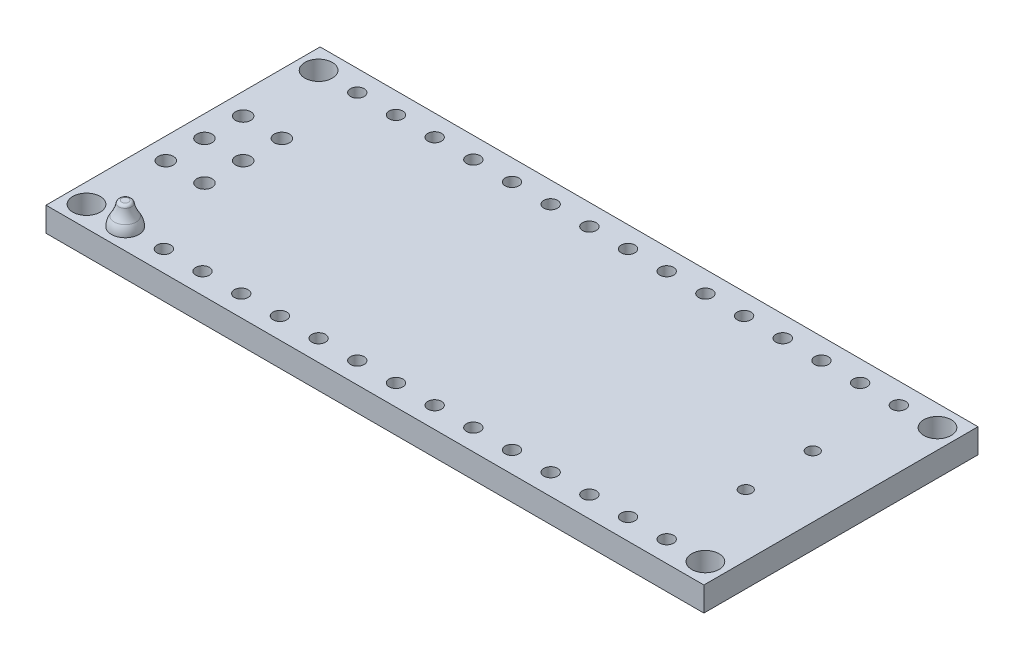
from build123d import *

# Parameters (mm, degrees)
SKETCH1_W            = 43.2
SKETCH1_H            = 18
BOSS_EXTRUDE2_DEPTH  = 1.6
SKETCH2_R            = 0.45
CUT_EXTRUDE2_DEPTH   = 1.6
LPATTERN1_COUNT      = 15
LPATTERN1_PITCH      = 2.54
SKETCH3_R            = 0.5
CUT_EXTRUDE4_DEPTH   = 1.6
SKETCH4_R            = 0.9
CUT_EXTRUDE5_DEPTH   = 1.6
LPATTERN3_COUNT      = 2
LPATTERN3_PITCH      = 2.54
LPATTERN3_COUNT_DIR2 = 3
LPATTERN3_PITCH_DIR2 = 2.54
SKETCH9_R            = 0.4
CUT_EXTRUDE6_DEPTH   = 10


with BuildPart() as part:
    # Sketch1 → Boss-Extrude2 (new body)
    with BuildSketch(Plane(origin=(0, 0, 0), x_dir=(1, 0, 0), z_dir=(0, 1, 0))):
        with Locations((17.78, 7.62)):
            Rectangle(SKETCH1_W, SKETCH1_H)
    extrude(amount=BOSS_EXTRUDE2_DEPTH)

    # Sketch2 → Cut-Extrude2 (cut)
    with BuildSketch(Plane(origin=(0, 0, 0), x_dir=(1, 0, 0), z_dir=(0, 1, 0))):
        Circle(SKETCH2_R)
        with Locations((0, 15.24)):
            Circle(SKETCH2_R)
    cut_extrude2 = extrude(amount=CUT_EXTRUDE2_DEPTH, mode=Mode.SUBTRACT)

    # LPattern1: Cut-Extrude2 ×15
    with Locations(*[(i * LPATTERN1_PITCH, 0, 0) for i in range(1, LPATTERN1_COUNT)]):
        add(cut_extrude2, mode=Mode.SUBTRACT)

    # Sketch3 → Cut-Extrude4 (cut)
    with BuildSketch(Plane(origin=(0, 0, 0), x_dir=(1, 0, 0), z_dir=(0, 1, 0))):
        with Locations((0.127, 10.16)):
            Circle(SKETCH3_R)
        with Locations((-2.413, 10.16)):
            Circle(SKETCH3_R)
        with Locations((-2.413, 7.62)):
            Circle(SKETCH3_R)
        with Locations((-2.413, 5.08)):
            Circle(SKETCH3_R)
        with Locations((0.127, 5.08)):
            Circle(SKETCH3_R)
        with Locations((0.127, 7.62)):
            Circle(SKETCH3_R)
    extrude(amount=CUT_EXTRUDE4_DEPTH, mode=Mode.SUBTRACT)

    # Sketch4 → Cut-Extrude5 (cut)
    with BuildSketch(Plane(origin=(0, 0, 0), x_dir=(1, 0, 0), z_dir=(0, 1, 0))):
        with Locations((38.1, 15.24)):
            Circle(SKETCH4_R)
        with Locations((38.1, 0)):
            Circle(SKETCH4_R)
        with Locations((-2.54, 0)):
            Circle(SKETCH4_R)
        with Locations((-2.54, 15.24)):
            Circle(SKETCH4_R)
    extrude(amount=CUT_EXTRUDE5_DEPTH, mode=Mode.SUBTRACT)

    # Sketch6 → Revolve1 (revolve)
    with BuildSketch(Plane(origin=(0, 0, 0), x_dir=(0, 0, -1), z_dir=(1, 0, 0))):
        with BuildLine():
            Line((0, 1.6), (0.9, 1.6))
            ThreePointArc((0.9, 1.6), (0.852442497, 1.91994498), (0.713882199, 2.212224898))
            ThreePointArc((0.713882199, 2.212224898), (0.530499248, 2.558589224), (0.422081551, 2.93520993))
            ThreePointArc((0.422081551, 2.93520993), (0.353575878, 3.053365554), (0.225205293, 3.1))
            Line((0.225205293, 3.1), (0, 3.1))
            Line((0, 3.1), (0, 1.6))
        make_face()
    revolve(axis=Axis((0, 1.372239532, 0), (0, 1, 0)))

    # Sketch7 → Revolve2 (revolve)
    with BuildSketch(Plane.XY.offset(-5.08)):
        with BuildLine():
            Line((0.127, 0), (1.027, 0))
            ThreePointArc((1.027, 0), (0.970551628, -0.347850543), (0.807, -0.66))
            ThreePointArc((0.807, -0.66), (0.629174555, -0.974977034), (0.537980562, -1.325))
            ThreePointArc((0.537980562, -1.325), (0.471836779, -1.45), (0.339549213, -1.5))
            Line((0.339549213, -1.5), (0.127, -1.5))
            Line((0.127, -1.5), (0.127, 0))
        make_face()
    revolve2 = revolve(axis=Axis((0.127, 3.888986093, -5.08), (0, -1, 0)))

    # LPattern3: Revolve2 2 × 3
    with Locations(*[(-i * LPATTERN3_PITCH, 0, -j * LPATTERN3_PITCH_DIR2) for i in range(LPATTERN3_COUNT) for j in range(LPATTERN3_COUNT_DIR2) if (i, j) != (0, 0)]):
        add(revolve2)

    # Sketch9 → Cut-Extrude6 (cut)
    with BuildSketch(Plane(origin=(0, 0, 0), x_dir=(1, 0, 0), z_dir=(0, 1, 0))):
        with Locations((35.33, 5.42)):
            Circle(SKETCH9_R)
        with Locations((35.33, 9.82)):
            Circle(SKETCH9_R)
    extrude(amount=CUT_EXTRUDE6_DEPTH, mode=Mode.SUBTRACT)


solid = part.part
